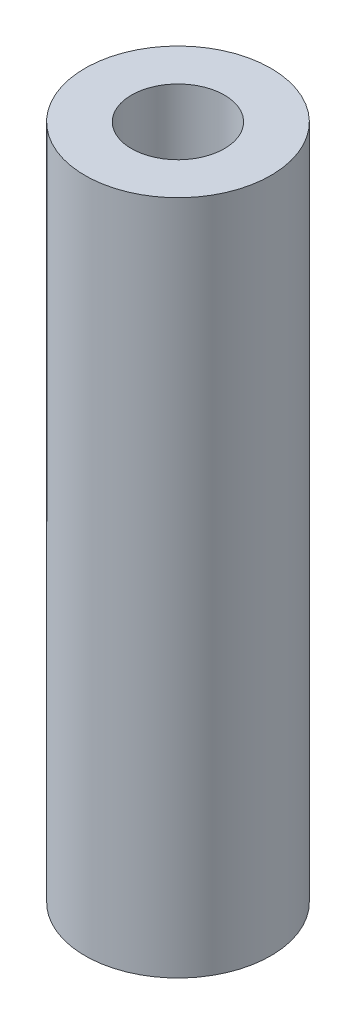
from build123d import *

# Parameters (mm, degrees)
SKETCH1_W = 5.5
SKETCH1_H = 80


with BuildPart() as part:
    # Sketch1 → Revolve1 (revolve)
    with BuildSketch(Plane.XY):
        with Locations((8.25, 40)):
            Rectangle(SKETCH1_W, SKETCH1_H)
    revolve(axis=Axis((0, 0, 0), (0, 1, 0)))


solid = part.part
